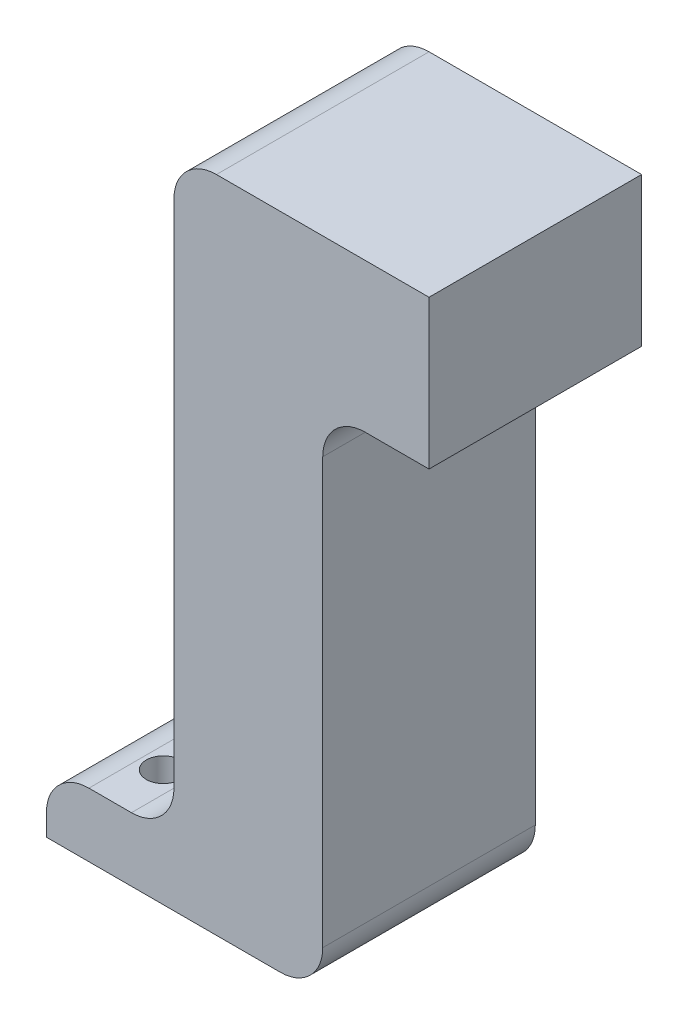
from build123d import *

# Parameters (mm, degrees)
SKETCH1_W                  = 1.5
SKETCH1_H                  = 0.75
BOSS_EXTRUDE1_DEPTH        = 1.875
BOSS_EXTRUDE1_DEPTH_BACK   = 0.625
FILLET1_R                  = 0.5
F_0_4_0_4_DIAMETER_HOLE1_D = 0.4


with BuildPart() as part:
    # Sketch1 → Boss-Extrude1 (new body, two sides)
    with BuildSketch(Plane.XY) as boss_extrude1_sk:
        Polygon((0.285769435, 0.25), (-1.464230565, 0.25), (-1.464230565, -5), (-1.464230565, -5.75), (0.285769435, -5.75), align=None)
        Polygon((-1.464230565, 2), (-1.464230565, 0.25), (0.285769435, 0.25), (1.535769435, 0.25), (1.535769435, 2), align=None)
        with Locations((-2.214230565, -5.375)):
            Rectangle(SKETCH1_W, SKETCH1_H)
    extrude(amount=BOSS_EXTRUDE1_DEPTH)
    extrude(boss_extrude1_sk.sketch, amount=-BOSS_EXTRUDE1_DEPTH_BACK)

    # Fillet1
    fillet1_edges = [part.edges().sort_by_distance(p)[0] for p in [
        (0.285769435, 0.25, 0.625),
        (-2.964230565, -5, 0.625),
        (-1.464230565, -5, 0.625),
        (0.285769435, -5.75, 0.625),
        (-1.464230565, 2, 0.625),
    ]]
    fillet(fillet1_edges, radius=FILLET1_R)

    # Ø0.4 (0.4) Diameter Hole1 (through all)
    with Locations(Plane(origin=(0, -5, 0), x_dir=(1, 0, 0), z_dir=(0, 1, 0))):
        with Locations((-2.214230565, 0), (-2.214230565, -1.25)):
            Hole(F_0_4_0_4_DIAMETER_HOLE1_D / 2)


solid = part.part
